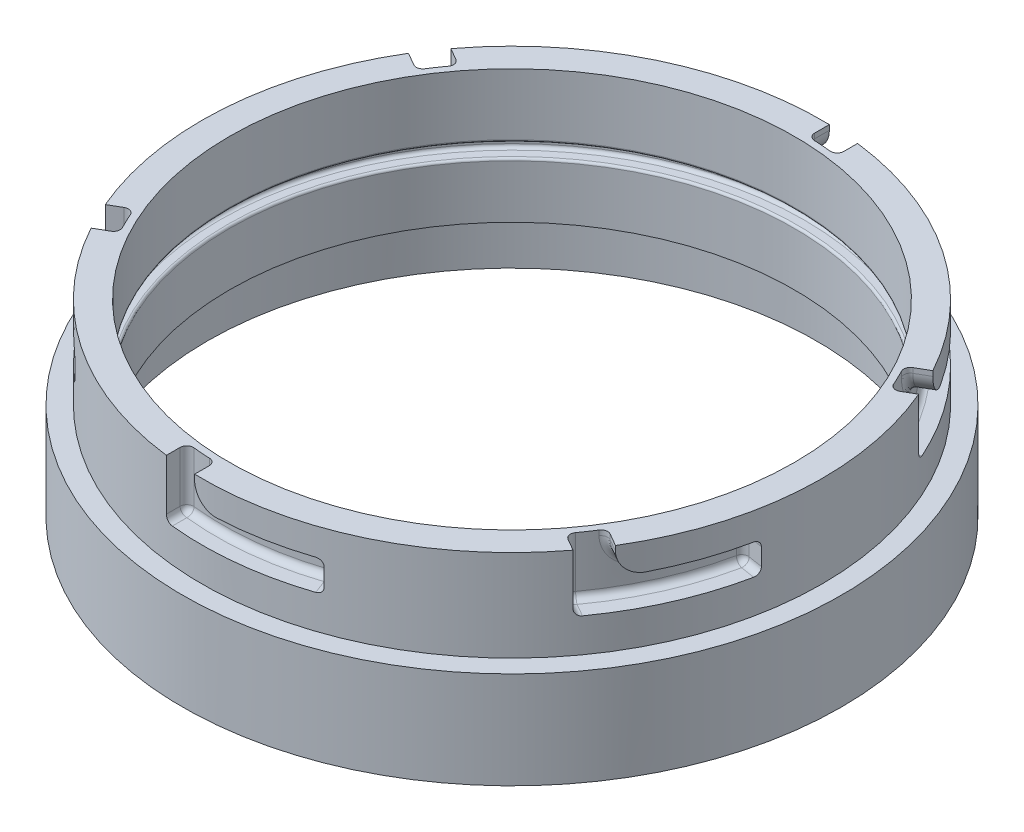
from build123d import *

# Parameters (mm, degrees)
CUT_EXTRUDE1_START       = -13.207999999999998
CUT_EXTRUDE1_DEPTH       = 13.207999999999998
SKETCH10_W               = 4.827435186195032
SKETCH10_H               = 6.984999999999999
FILLET1_R                = 5.08
FILLET7_R                = 1.524
CIRPATTERN1_COUNT        = 6
FILLET1_OF_CIRPATTERN1_R = 5.08
FILLET7_OF_CIRPATTERN1_R = 1.524
FILLET2_R                = 0.762
FILLET3_R                = 0.508
BOSS_EXTRUDE1_START      = 12.7
SKETCH25_R               = 75.565
SKETCH25_R_2             = 69.85
BOSS_EXTRUDE1_DEPTH      = 12.7
FILLET8_R                = 0.762


with BuildPart() as part:
    # Sketch1 → Revolve1 (revolve)
    with BuildSketch(Plane.XY):
        Polygon((71.11999999999999, 36.51250000000001), (71.11999999999999, 15.557500000000015), (75.56500000000001, 15.557500000000017), (75.565, 6.032500000000017), (64.77000000000001, 6.032500000000014), (64.77000000000001, 18.732500000000012), (67.81799999999998, 18.732500000000012), (67.81799999999998, 21.907500000000017), (64.77, 21.907500000000013), (64.77, 36.51250000000001), align=None)
    revolve(axis=Axis((0, 60.75795454545431, 0), (1.2e-16, -1, 0)))

    # Sketch2 → Cut-Extrude1 (cut)
    with BuildSketch(Plane(origin=(-4.47e-15, 36.5125, 0), x_dir=(1, 1.2e-16, 0), z_dir=(-1.2e-16, 1, 0)).offset(CUT_EXTRUDE1_START)):
        with BuildLine():
            Line((-8.659215820595662, -70.59088029889091), (-8.659215820595662, -65.7260406336206))
            ThreePointArc((-8.659215820595662, -65.7260406336206), (-5.173944735082208, -66.09179020028368), (-1.6742158205956637, -66.27285596219667))
            Line((-1.6742158205956637, -66.27285596219667), (-1.6742158205956637, -71.1002911483917))
            ThreePointArc((-1.6742158205956637, -71.1002911483917), (-5.172990162777308, -70.93161899164441), (-8.659215820595662, -70.59088029889091))
        make_face()
    cut_extrude1 = extrude(amount=CUT_EXTRUDE1_DEPTH, mode=Mode.SUBTRACT)

    # Cut-Sweep2: sweep along a path in Sketch23
    with BuildLine(Plane(origin=(-2.85e-15, 23.304500000000004, 0), x_dir=(1, 1.2e-16, 0), z_dir=(-1.2e-16, 1, 0))) as cut_sweep2_path:
        ThreePointArc((-1.6742158205956639, -71.1002911483917), (11.313422517678514, -70.21439219231685), (23.92201927626626, -66.97605089691348))
    # Sketch10 → Cut-Sweep2 (sweep, cut)
    with BuildSketch(Plane.ZY.offset(1.6742158205956639)):
        with Locations((68.68657355529419, 26.797000000000008)):
            Rectangle(SKETCH10_W, SKETCH10_H)
    cut_sweep2 = sweep(path=cut_sweep2_path.line, mode=Mode.SUBTRACT)

    # Fillet1
    fillet1_edges = [part.edges().sort_by_distance(p)[0] for p in [
        (-1.6742158205956676, 30.289500000000007, 68.68657355529419),
    ]]
    fillet(fillet1_edges, radius=FILLET1_R)

    # Fillet7
    fillet7_edges = [part.edges().sort_by_distance(p)[0] for p in [
        (-1.6742158205956668, 35.941, 66.27285596219667),
        (-0.18582286684972038, 31.776902176794007, 66.29373957046366),
        (23.05685308016756, 23.304500000000004, 64.72271557513899),
        (-8.659215820595666, 23.304500000000004, 68.15846046625575),
        (23.05685308016756, 30.289500000000007, 64.72271557513899),
        (22.191686884068872, 26.797000000000004, 62.46938025336449),
        (12.934414118168412, 30.289500000000007, 65.01996129974029),
        (6.95941107271422, 23.304500000000004, 65.92769549681668),
        (-8.659215820595668, 29.908500000000004, 65.7260406336206),
    ]]
    fillet(fillet7_edges, radius=FILLET7_R)

    # CirPattern1: Cut-Extrude1, Cut-Sweep2 ×6 about axis
    cirpattern1_axis = Axis((0, 60.75795454545431, 0), (-1.2e-16, 1, 0))
    add([cut_extrude1.rotate(cirpattern1_axis, i * 360 / CIRPATTERN1_COUNT) for i in range(1, CIRPATTERN1_COUNT)], mode=Mode.SUBTRACT)
    add([cut_sweep2.rotate(cirpattern1_axis, i * 360 / CIRPATTERN1_COUNT) for i in range(1, CIRPATTERN1_COUNT)], mode=Mode.SUBTRACT)

    # Fillet1 of CirPattern1
    fillet1_of_cirpattern1_edges = [part.edges().sort_by_distance(p)[0] for p in [
        (58.64720968749536, 30.289500000000015, 35.793200209700764),
        (60.321425508091046, 30.289500000000015, -32.89337334559342),
        (1.6742158205956834, 30.289500000000007, -68.68657355529419),
        (-58.647209687495334, 30.2895, -35.793200209700785),
        (-60.321425508091025, 30.2895, 32.89337334559344),
    ]]
    fillet(fillet1_of_cirpattern1_edges, radius=FILLET1_OF_CIRPATTERN1_R)

    # Fillet7 of CirPattern1
    fillet7_of_cirpattern1_edges = [part.edges().sort_by_distance(p)[0] for p in [
        (56.55686893431148, 35.94100000000001, 34.586341413152006),
        (57.31915114646635, 31.776902176794014, 33.30779710852775),
        (67.5799424300689, 23.30450000000001, 12.393537288818921),
        (54.697350336316994, 23.30450000000001, 41.57833111061584),
        (67.5799424300689, 30.289500000000015, 12.39353728881892),
        (65.19591370011806, 26.797000000000008, 12.016125532248683),
        (62.776145297740364, 30.289500000000015, 21.308449440468213),
        (60.574764649565296, 23.30450000000001, 26.936820964059127),
        (52.590812968585865, 29.90850000000001, 40.362121194298275),
        (58.23108475490716, 35.94100000000001, -31.68651454904466),
        (57.50497401331608, 31.776902176794014, -32.9859424619359),
        (44.52308934990136, 23.304500000000008, -52.329178286320065),
        (63.35656615691267, 23.30450000000001, -26.580129355639894),
        (44.52308934990136, 30.28950000000001, -52.329178286320065),
        (43.004226816049204, 26.797000000000008, -50.453254721115805),
        (49.841731179571966, 30.28950000000001, -43.71151185927207),
        (53.615353576851085, 23.30450000000001, -38.990874532757545),
        (61.25002878918154, 29.90850000000001, -25.36391943932232),
        (1.674215820595681, 35.941, -66.27285596219667),
        (0.1858228668497356, 31.776902176794007, -66.29373957046366),
        (-23.056853080167542, 23.304499999999997, -64.72271557513899),
        (8.659215820595682, 23.304500000000008, -68.15846046625575),
        (-23.056853080167546, 30.2895, -64.72271557513899),
        (-22.191686884068858, 26.796999999999997, -62.46938025336449),
        (-12.934414118168398, 30.289500000000004, -65.01996129974029),
        (-6.959411072714202, 23.304500000000004, -65.92769549681668),
        (8.659215820595682, 29.908500000000007, -65.7260406336206),
        (-56.55686893431146, 35.940999999999995, -34.58634141315203),
        (-57.319151146466325, 31.776902176794, -33.30779710852777),
        (-67.57994243006888, 23.304499999999994, -12.393537288818946),
        (-54.697350336316966, 23.304499999999997, -41.57833111061586),
        (-67.57994243006888, 30.289499999999997, -12.393537288818944),
        (-65.19591370011804, 26.796999999999993, -12.016125532248708),
        (-62.77614529774034, 30.289499999999997, -21.308449440468237),
        (-60.57476464956527, 23.304499999999997, -26.93682096405915),
        (-52.59081296858584, 29.908499999999997, -40.36212119429829),
        (-58.231084754907144, 35.940999999999995, 31.686514549044684),
        (-57.50497401331606, 31.776902176794, 32.98594246193592),
        (-44.52308934990133, 23.304499999999997, 52.32917828632009),
        (-63.356566156912656, 23.304499999999997, 26.580129355639915),
        (-44.52308934990133, 30.2895, 52.32917828632009),
        (-43.004226816049176, 26.796999999999997, 50.45325472111582),
        (-49.841731179571944, 30.2895, 43.711511859272086),
        (-53.615353576851064, 23.304499999999997, 38.990874532757566),
        (-61.25002878918153, 29.908499999999997, 25.36391943932234),
    ]]
    fillet(fillet7_of_cirpattern1_edges, radius=FILLET7_OF_CIRPATTERN1_R)

    # Fillet2
    fillet2_edges = [part.edges().sort_by_distance(p)[0] for p in [
        (-67.81799999999998, 21.9075, 8.31e-15),
        (-67.81799999999998, 18.7325, 8.31e-15),
    ]]
    fillet(fillet2_edges, radius=FILLET2_R)

    # Fillet3
    fillet3_edges = [part.edges().sort_by_distance(p)[0] for p in [
        (-64.77000000000001, 18.7325, 7.93e-15),
        (-64.77, 21.9075, 7.93e-15),
    ]]
    fillet(fillet3_edges, radius=FILLET3_R)

    # Sketch25 → Boss-Extrude1 (add)
    with BuildSketch(Plane.XZ.offset(-6.032500000000007).offset(BOSS_EXTRUDE1_START)):
        Circle(SKETCH25_R)
        Circle(SKETCH25_R_2, mode=Mode.SUBTRACT)
    extrude(amount=-BOSS_EXTRUDE1_DEPTH)

    # Fillet8
    fillet8_edges = [part.edges().sort_by_distance(p)[0] for p in [
        (-69.85, 6.032499999999998, 8.55e-15),
    ]]
    fillet(fillet8_edges, radius=FILLET8_R)


solid = part.part
